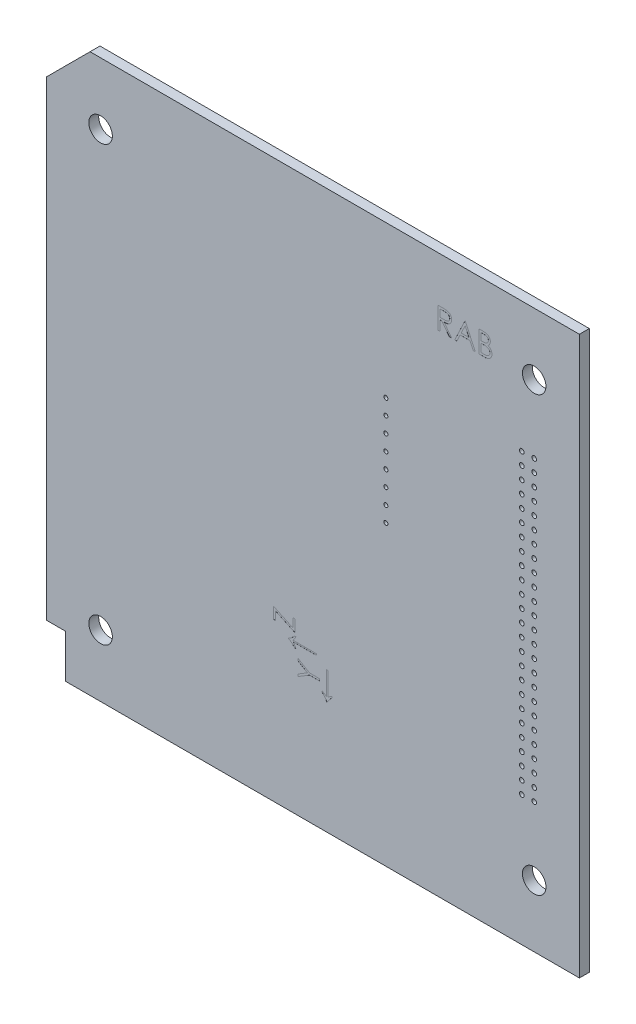
from build123d import *

# Parameters (mm, degrees)
SKETCH1_W           = 86
SKETCH1_H           = 90
SKETCH1_R           = 1.9
SKETCH1_R_2         = 0.375
SKETCH1_R_3         = 0.383755901
SKETCH1_R_4         = 0.384163196
SKETCH1_R_5         = 0.380771211
SKETCH1_R_6         = 0.377379225
SKETCH1_R_7         = 0.380832793
BOSS_EXTRUDE1_DEPTH = 1.6
SKETCH2_R           = 0.325
EXTRUDE1_DEPTH      = 2.6
CUT_EXTRUDE_1_DEPTH = 0.01
CUT_EXTRUDE_2_DEPTH = 0.01
SKETCH_3_W          = 3
SKETCH_3_H          = 7
CUT_EXTRUDE_3_DEPTH = 10


with BuildPart() as part:
    # Sketch1 → Boss-Extrude1 (new body)
    with BuildSketch(Plane.XY):
        with Locations((-43, -45)):
            Rectangle(SKETCH1_W, SKETCH1_H)
        with Locations((-7.3, -10)):
            Circle(SKETCH1_R, mode=Mode.SUBTRACT)
        with Locations((-77.3, -10)):
            Circle(SKETCH1_R, mode=Mode.SUBTRACT)
        with Locations((-77.3, -80)):
            Circle(SKETCH1_R, mode=Mode.SUBTRACT)
        with Locations((-7.3, -80)):
            Circle(SKETCH1_R, mode=Mode.SUBTRACT)
        with Locations((-9.3, -69)):
            Circle(SKETCH1_R_2, mode=Mode.SUBTRACT)
        with Locations((-7.3, -69)):
            Circle(SKETCH1_R_2, mode=Mode.SUBTRACT)
        with Locations((-7.3, -67)):
            Circle(SKETCH1_R_2, mode=Mode.SUBTRACT)
        with Locations((-9.3, -67)):
            Circle(SKETCH1_R_2, mode=Mode.SUBTRACT)
        with Locations((-9.3, -65)):
            Circle(SKETCH1_R_2, mode=Mode.SUBTRACT)
        with Locations((-7.3, -65)):
            Circle(SKETCH1_R_2, mode=Mode.SUBTRACT)
        with Locations((-7.3, -63)):
            Circle(SKETCH1_R_2, mode=Mode.SUBTRACT)
        with Locations((-9.3, -63)):
            Circle(SKETCH1_R_3, mode=Mode.SUBTRACT)
        with Locations((-9.3, -61)):
            Circle(SKETCH1_R_2, mode=Mode.SUBTRACT)
        with Locations((-7.3, -61)):
            Circle(SKETCH1_R_2, mode=Mode.SUBTRACT)
        with Locations((-7.3, -59)):
            Circle(SKETCH1_R_2, mode=Mode.SUBTRACT)
        with Locations((-9.3, -59)):
            Circle(SKETCH1_R_2, mode=Mode.SUBTRACT)
        with Locations((-7.3, -57)):
            Circle(SKETCH1_R_2, mode=Mode.SUBTRACT)
        with Locations((-9.3, -57)):
            Circle(SKETCH1_R_2, mode=Mode.SUBTRACT)
        with Locations((-9.3, -55)):
            Circle(SKETCH1_R_2, mode=Mode.SUBTRACT)
        with Locations((-7.3, -55)):
            Circle(SKETCH1_R_2, mode=Mode.SUBTRACT)
        with Locations((-7.3, -53)):
            Circle(SKETCH1_R_2, mode=Mode.SUBTRACT)
        with Locations((-9.3, -53)):
            Circle(SKETCH1_R_2, mode=Mode.SUBTRACT)
        with Locations((-9.3, -51)):
            Circle(SKETCH1_R_2, mode=Mode.SUBTRACT)
        with Locations((-7.3, -51)):
            Circle(SKETCH1_R_2, mode=Mode.SUBTRACT)
        with Locations((-7.3, -49)):
            Circle(SKETCH1_R_2, mode=Mode.SUBTRACT)
        with Locations((-9.3, -49)):
            Circle(SKETCH1_R_2, mode=Mode.SUBTRACT)
        with Locations((-9.3, -47)):
            Circle(SKETCH1_R_2, mode=Mode.SUBTRACT)
        with Locations((-7.3, -47)):
            Circle(SKETCH1_R_2, mode=Mode.SUBTRACT)
        with Locations((-7.3, -45)):
            Circle(SKETCH1_R_2, mode=Mode.SUBTRACT)
        with Locations((-9.3, -45)):
            Circle(SKETCH1_R_4, mode=Mode.SUBTRACT)
        with Locations((-9.3, -43)):
            Circle(SKETCH1_R_2, mode=Mode.SUBTRACT)
        with Locations((-7.3, -43)):
            Circle(SKETCH1_R_5, mode=Mode.SUBTRACT)
        with Locations((-7.3, -41)):
            Circle(SKETCH1_R_6, mode=Mode.SUBTRACT)
        with Locations((-9.3, -41)):
            Circle(SKETCH1_R_6, mode=Mode.SUBTRACT)
        with Locations((-9.3, -39)):
            Circle(SKETCH1_R_2, mode=Mode.SUBTRACT)
        with Locations((-7.3, -39)):
            Circle(SKETCH1_R_2, mode=Mode.SUBTRACT)
        with Locations((-7.3, -37)):
            Circle(SKETCH1_R_2, mode=Mode.SUBTRACT)
        with Locations((-9.3, -37)):
            Circle(SKETCH1_R_7, mode=Mode.SUBTRACT)
        with Locations((-7.3, -35)):
            Circle(SKETCH1_R_2, mode=Mode.SUBTRACT)
        with Locations((-9.3, -35)):
            Circle(SKETCH1_R_2, mode=Mode.SUBTRACT)
        with Locations((-9.3, -33)):
            Circle(SKETCH1_R_2, mode=Mode.SUBTRACT)
        with Locations((-7.3, -33)):
            Circle(SKETCH1_R_2, mode=Mode.SUBTRACT)
        with Locations((-7.3, -31)):
            Circle(SKETCH1_R_2, mode=Mode.SUBTRACT)
        with Locations((-9.3, -31)):
            Circle(SKETCH1_R_2, mode=Mode.SUBTRACT)
        with Locations((-7.3, -29)):
            Circle(SKETCH1_R_2, mode=Mode.SUBTRACT)
        with Locations((-9.3, -29)):
            Circle(SKETCH1_R_2, mode=Mode.SUBTRACT)
        with Locations((-9.3, -27)):
            Circle(SKETCH1_R_2, mode=Mode.SUBTRACT)
        with Locations((-7.3, -27)):
            Circle(SKETCH1_R_2, mode=Mode.SUBTRACT)
        with Locations((-7.3, -25)):
            Circle(SKETCH1_R_2, mode=Mode.SUBTRACT)
        with Locations((-9.3, -25)):
            Circle(SKETCH1_R_2, mode=Mode.SUBTRACT)
        with Locations((-7.3, -23)):
            Circle(SKETCH1_R_2, mode=Mode.SUBTRACT)
        with Locations((-9.3, -23)):
            Circle(SKETCH1_R_2, mode=Mode.SUBTRACT)
        with Locations((-9.3, -21)):
            Circle(SKETCH1_R_2, mode=Mode.SUBTRACT)
        with Locations((-7.3, -21)):
            Circle(SKETCH1_R_2, mode=Mode.SUBTRACT)
    extrude(amount=BOSS_EXTRUDE1_DEPTH)

    # Sketch2 → Extrude1 (cut, through all)
    with BuildSketch(Plane(origin=(0, 0, 0), x_dir=(-1, 0, 0), z_dir=(0, 0, -1))):
        with Locations((31.24, -24.5)):
            Circle(SKETCH2_R)
        with Locations((31.24, -27)):
            Circle(SKETCH2_R)
        with Locations((31.24, -29.5)):
            Circle(SKETCH2_R)
        with Locations((31.24, -32)):
            Circle(SKETCH2_R)
        with Locations((31.24, -34.5)):
            Circle(SKETCH2_R)
        with Locations((31.24, -37)):
            Circle(SKETCH2_R)
        with Locations((31.24, -39.5)):
            Circle(SKETCH2_R)
        with Locations((31.24, -42)):
            Circle(SKETCH2_R)
    extrude(amount=-EXTRUDE1_DEPTH, mode=Mode.SUBTRACT)

    # ｽｹｯﾁ1 → ｶｯﾄ - 押し出し1 (cut)
    with BuildSketch(Plane.XY.offset(1.6)):
        Polygon((-45.422907979, -70.570488191), (-45.422907979, -70.210812711), (-43.919001729, -69.290940916), (-45.422907979, -68.372471365), (-45.422907979, -68.012795884), (-43.586669998, -69.134590756), (-41.922907979, -69.134590756), (-41.922907979, -69.44869332), (-43.586669998, -69.44869332), align=None)
        Polygon((-49.042559529, -64.546795723), (-49.401533888, -64.546795723), (-49.401533888, -62.707052133), (-46.260508247, -64.175201171), (-46.260508247, -62.751923928), (-45.901533888, -62.751923928), (-45.901533888, -64.681411107), (-49.042559529, -63.213262069), align=None)
        with BuildLine():
            Line((-41.56393362, -70.795548288), (-41.56393362, -70.615359986))
            add(Edge.make_bspline(
                [(-41.56393362, -70.615359986), (-41.499275148, -70.647342808), (-41.370863205, -70.710860801), (-41.186484381, -70.818425521), (-41.011058478, -70.935514502), (-40.900873489, -71.02132933), (-40.845984902, -71.064077935)],
                knots=[0, 0, 0, 0, 0.000216356, 0.000429684, 0.000639892, 0.000848549, 0.000848549, 0.000848549, 0.000848549], degree=3))
            Line((-40.845984902, -71.064077935), (-40.845984902, -67.294847166))
            Line((-40.845984902, -67.294847166), (-40.621625927, -67.294847166))
            Line((-40.621625927, -67.294847166), (-40.621625927, -71.064077935))
            add(Edge.make_bspline(
                [(-40.621625927, -71.064077935), (-40.600816779, -71.0446585), (-40.557772691, -71.004489058), (-40.486789169, -70.947470675), (-40.408453665, -70.890330816), (-40.322628678, -70.833866724), (-40.228604195, -70.778342841), (-40.127292783, -70.723265113), (-40.018271274, -70.668434457), (-39.942574563, -70.633375374), (-39.903677209, -70.615359986)],
                knots=[0, 0, 0, 0, 8.5364e-05, 0.000176578, 0.00027292, 0.000376178, 0.000484637, 0.000600409, 0.000722067, 0.000850661, 0.000850661, 0.000850661, 0.000850661], degree=3))
            Line((-39.903677209, -70.615359986), (-39.903677209, -70.797651653))
            add(Edge.make_bspline(
                [(-39.903677209, -70.797651653), (-39.950753646, -70.841002938), (-40.042448627, -70.925442109), (-40.170801438, -71.054617033), (-40.287259171, -71.181411976), (-40.392178824, -71.305578527), (-40.485017832, -71.427258879), (-40.565088834, -71.547148407), (-40.635040188, -71.663686429), (-40.672272203, -71.743367976), (-40.690335863, -71.782026653)],
                knots=[0, 0, 0, 0, 0.00019197, 0.000373918, 0.00054611, 0.000708325, 0.000861453, 0.001004962, 0.001140721, 0.001268656, 0.001268656, 0.001268656, 0.001268656], degree=3))
            Line((-40.690335863, -71.782026653), (-40.792699645, -71.782026653))
            add(Edge.make_bspline(
                [(-40.792699645, -71.782026653), (-40.80825239, -71.745995378), (-40.840725997, -71.670763292), (-40.903281301, -71.558626453), (-40.979699583, -71.442315707), (-41.068767232, -71.320615708), (-41.173074063, -71.195665554), (-41.290558909, -71.065701156), (-41.421747945, -70.931214432), (-41.515501036, -70.84176013), (-41.56393362, -70.795548288)],
                knots=[0, 0, 0, 0, 0.000117676, 0.000245703, 0.000384553, 0.000535022, 0.000697865, 0.000872603, 0.001060516, 0.001261332, 0.001261332, 0.001261332, 0.001261332], degree=3))
        make_face()
        with BuildLine():
            Line((-45.947106805, -65.175000851), (-45.766918503, -65.175000851))
            add(Edge.make_bspline(
                [(-45.766918503, -65.175000851), (-45.798854445, -65.239687492), (-45.862189921, -65.367974273), (-45.970418722, -65.551943755), (-46.086822599, -65.72780807), (-46.172844311, -65.838089334), (-46.215636452, -65.892949569)],
                knots=[0, 0, 0, 0, 0.000216356, 0.000429078, 0.000639869, 0.000848526, 0.000848526, 0.000848526, 0.000848526], degree=3))
            Line((-46.215636452, -65.892949569), (-42.446405683, -65.892949569))
            Line((-42.446405683, -65.892949569), (-42.446405683, -66.117308543))
            Line((-42.446405683, -66.117308543), (-46.215636452, -66.117308543))
            add(Edge.make_bspline(
                [(-46.215636452, -66.117308543), (-46.196217017, -66.138117692), (-46.156047575, -66.18116178), (-46.099029192, -66.252145302), (-46.041889333, -66.330480805), (-45.985425241, -66.416305792), (-45.929901358, -66.510330275), (-45.87482363, -66.611641688), (-45.819992974, -66.720663196), (-45.784933891, -66.796359907), (-45.766918503, -66.835257261)],
                knots=[0, 0, 0, 0, 8.5364e-05, 0.000176578, 0.00027292, 0.000376178, 0.000484637, 0.000600409, 0.000722067, 0.000850661, 0.000850661, 0.000850661, 0.000850661], degree=3))
            Line((-45.766918503, -66.835257261), (-45.94921017, -66.835257261))
            add(Edge.make_bspline(
                [(-45.94921017, -66.835257261), (-45.992561455, -66.788180825), (-46.077000625, -66.696485843), (-46.20617555, -66.568133033), (-46.332970493, -66.451675299), (-46.457137043, -66.346755647), (-46.578817396, -66.253916639), (-46.698706924, -66.173845636), (-46.815244946, -66.103894283), (-46.894926493, -66.066662268), (-46.93358517, -66.048598607)],
                knots=[0, 0, 0, 0, 0.00019197, 0.000373918, 0.00054611, 0.000708325, 0.000861453, 0.001004962, 0.001140721, 0.001268656, 0.001268656, 0.001268656, 0.001268656], degree=3))
            Line((-46.93358517, -66.048598607), (-46.93358517, -65.946234825))
            add(Edge.make_bspline(
                [(-46.93358517, -65.946234825), (-46.897551608, -65.930685118), (-46.822314747, -65.898217853), (-46.710217249, -65.8356103), (-46.593621286, -65.759340687), (-46.47265015, -65.669320851), (-46.34693469, -65.565983816), (-46.217312941, -65.448309213), (-46.08275813, -65.317204983), (-45.993313599, -65.223439722), (-45.947106805, -65.175000851)],
                knots=[0, 0, 0, 0, 0.000117676, 0.000245703, 0.000384553, 0.000535438, 0.000697835, 0.000872573, 0.001060486, 0.001261302, 0.001261302, 0.001261302, 0.001261302], degree=3))
        make_face()
    extrude(amount=-CUT_EXTRUDE_1_DEPTH, mode=Mode.SUBTRACT)

    # ｽｹｯﾁ2 → ｶｯﾄ - 押し出し2 (cut)
    with BuildSketch(Plane.XY.offset(1.6)):
        with BuildLine():
            Line((-22.820494347, -7.351233874), (-22.120073674, -7.351233874))
            add(Edge.make_bspline(
                [(-22.120073674, -7.351233874), (-22.073332546, -7.35138946), (-21.983584401, -7.351688202), (-21.855011131, -7.353353965), (-21.738184034, -7.358128321), (-21.633164195, -7.362236904), (-21.53995354, -7.369728846), (-21.458266249, -7.376889493), (-21.388478552, -7.386263154), (-21.3462327, -7.394968576), (-21.327104924, -7.398910156)],
                knots=[0, 0, 0, 0, 0.000140226, 0.00026925, 0.000385712, 0.000490995, 0.000584507, 0.000666202, 0.000736998, 0.000795574, 0.000795574, 0.000795574, 0.000795574], degree=3))
            add(Edge.make_bspline(
                [(-21.327104924, -7.398910156), (-21.3014983, -7.405236921), (-21.250831311, -7.417755485), (-21.177881245, -7.444215086), (-21.108366921, -7.47483471), (-21.042577096, -7.510798431), (-20.980841305, -7.55237321), (-20.922522994, -7.598841333), (-20.867357531, -7.649948539), (-20.817575901, -7.70698338), (-20.770636849, -7.76681989), (-20.731048223, -7.831523647), (-20.696921743, -7.899185174), (-20.669751226, -7.970492592), (-20.647873253, -8.044754364), (-20.632447013, -8.12264316), (-20.623195826, -8.203804136), (-20.62225397, -8.259162044), (-20.621776399, -8.28723147)],
                knots=[0, 0, 0, 0, 7.9081e-05, 0.000156475, 0.000232432, 0.000306798, 0.00038108, 0.000455429, 0.000530331, 0.000606314, 0.000682321, 0.000758201, 0.000833453, 0.000909362, 0.000986794, 0.001065445, 0.001147284, 0.001231465, 0.001231465, 0.001231465, 0.001231465], degree=3))
            add(Edge.make_bspline(
                [(-20.621776399, -8.28723147), (-20.623245397, -8.333866575), (-20.626111793, -8.424863743), (-20.652836896, -8.556924624), (-20.696613416, -8.680113939), (-20.756936705, -8.794276577), (-20.833756181, -8.897187222), (-20.926080972, -8.987577677), (-21.033962583, -9.06321759), (-21.134391899, -9.115670394), (-21.223106099, -9.149263303), (-21.296139412, -9.172899662), (-21.375806389, -9.191161627), (-21.461343724, -9.207521759), (-21.553107379, -9.219873453), (-21.650877419, -9.228920048), (-21.75472357, -9.234574097), (-21.82606264, -9.235416101), (-21.862761976, -9.235849259)],
                knots=[0, 0, 0, 0, 0.000139777, 0.000272741, 0.000402249, 0.000530843, 0.000658588, 0.000786009, 0.000916741, 0.001052522, 0.001124656, 0.001201155, 0.001282612, 0.001369656, 0.001462366, 0.001560247, 0.001664165, 0.001774261, 0.001774261, 0.001774261, 0.001774261], degree=3))
            Line((-21.862761976, -9.235849259), (-20.576904604, -10.851233874))
            Line((-20.576904604, -10.851233874), (-20.965326078, -10.851233874))
            Line((-20.965326078, -10.851233874), (-22.25118345, -9.235849259))
            Line((-22.25118345, -9.235849259), (-22.506391783, -9.235849259))
            Line((-22.506391783, -9.235849259), (-22.506391783, -10.851233874))
            Line((-22.506391783, -10.851233874), (-22.820494347, -10.851233874))
            Line((-22.820494347, -10.851233874), (-22.820494347, -7.351233874))
        make_face()
        with BuildLine():
            Line((-22.506391783, -7.710208233), (-22.506391783, -8.8768749))
            Line((-22.506391783, -8.8768749), (-21.865566463, -8.881782752))
            add(Edge.make_bspline(
                [(-21.865566463, -8.881782752), (-21.835646424, -8.881795989), (-21.777652867, -8.881821645), (-21.693752202, -8.877827869), (-21.61563209, -8.873284551), (-21.543591338, -8.866335205), (-21.477597763, -8.857379133), (-21.41768435, -8.846176149), (-21.363753298, -8.833124087), (-21.300854759, -8.812922461), (-21.230618228, -8.780916442), (-21.154286768, -8.734350944), (-21.08928443, -8.675781825), (-21.034366568, -8.608808369), (-20.990237137, -8.53517212), (-20.959125082, -8.45575575), (-20.93938264, -8.372564152), (-20.937054094, -8.315386045), (-20.935878963, -8.286530348)],
                knots=[0, 0, 0, 0, 8.9746e-05, 0.000173954, 0.000251933, 0.000324488, 0.000391021, 0.000451663, 0.000507268, 0.000557378, 0.000649639, 0.000738152, 0.000824558, 0.000910739, 0.000997194, 0.001080909, 0.00116578, 0.001252248, 0.001252248, 0.001252248, 0.001252248], degree=3))
            add(Edge.make_bspline(
                [(-20.935878963, -8.286530348), (-20.937081084, -8.258383775), (-20.939463249, -8.202607536), (-20.958912018, -8.120951626), (-20.991801399, -8.043884675), (-21.036123637, -7.97172019), (-21.090122792, -7.906214455), (-21.153440605, -7.850167302), (-21.2243458, -7.803917837), (-21.290616998, -7.774363456), (-21.349851211, -7.756243603), (-21.401280871, -7.743492439), (-21.459392349, -7.73324797), (-21.524467807, -7.725039909), (-21.596229438, -7.717984965), (-21.675040089, -7.713233187), (-21.760376869, -7.710419322), (-21.8195238, -7.710280234), (-21.850141783, -7.710208233)],
                knots=[0, 0, 0, 0, 8.4371e-05, 0.000167192, 0.000250141, 0.000334794, 0.000420435, 0.000503871, 0.000587493, 0.000673488, 0.0007205, 0.000773215, 0.000832351, 0.0008974, 0.000969955, 0.001048634, 0.001134217, 0.001226067, 0.001226067, 0.001226067, 0.001226067], degree=3))
            Line((-21.850141783, -7.710208233), (-22.506391783, -7.710208233))
        make_face(mode=Mode.SUBTRACT)
        Polygon((-18.42305845, -7.351233874), (-16.807673835, -10.851233874), (-17.149120149, -10.851233874), (-17.666548033, -9.729439002), (-19.253186655, -9.729439002), (-19.785338097, -10.851233874), (-20.128186655, -10.851233874), (-18.467930245, -7.351233874), align=None)
        Polygon((-18.448999956, -8.03342538), (-19.082814059, -9.370464643), (-17.832012777, -9.370464643), align=None, mode=Mode.SUBTRACT)
        with BuildLine():
            Line((-16.179468706, -7.351233874), (-15.496576078, -7.351233874))
            add(Edge.make_bspline(
                [(-15.496576078, -7.351233874), (-15.4631476, -7.351409624), (-15.39835489, -7.351750272), (-15.304135448, -7.357033403), (-15.215886637, -7.364237073), (-15.133582865, -7.375667166), (-15.057262163, -7.389458943), (-14.986694525, -7.406160759), (-14.922104353, -7.426187373), (-14.844991617, -7.458033654), (-14.757070956, -7.505356822), (-14.661872563, -7.575285388), (-14.580468324, -7.660817851), (-14.510282006, -7.757300506), (-14.454480887, -7.863436278), (-14.414111589, -7.976695467), (-14.388553714, -8.095617209), (-14.38592528, -8.177260386), (-14.384596912, -8.218521534)],
                knots=[0, 0, 0, 0, 0.00010027, 0.000194349, 0.000283026, 0.000365821, 0.000443519, 0.000515622, 0.000583254, 0.00064614, 0.000765662, 0.000881909, 0.000998927, 0.001118415, 0.001238844, 0.00135727, 0.001478274, 0.001601912, 0.001601912, 0.001601912, 0.001601912], degree=3))
            add(Edge.make_bspline(
                [(-14.384596912, -8.218521534), (-14.38569013, -8.25717409), (-14.387838407, -8.333130007), (-14.408381167, -8.444224116), (-14.440541835, -8.549975335), (-14.485247084, -8.64999772), (-14.54334908, -8.742031334), (-14.612207399, -8.8268186), (-14.695284202, -8.900769657), (-14.757527442, -8.942112559), (-14.789144187, -8.96311288)],
                knots=[0, 0, 0, 0, 0.000115857, 0.00022767, 0.000337672, 0.000446877, 0.000555233, 0.000663318, 0.000773539, 0.000887324, 0.000887324, 0.000887324, 0.000887324], degree=3))
            add(Edge.make_bspline(
                [(-14.789144187, -8.96311288), (-14.74938376, -8.978377879), (-14.673312212, -9.007583604), (-14.5686262, -9.059219068), (-14.478431355, -9.115381178), (-14.402034209, -9.176713028), (-14.336696554, -9.242821839), (-14.279643612, -9.314676953), (-14.230962238, -9.393215711), (-14.189249315, -9.477619246), (-14.156700559, -9.567025715), (-14.132324654, -9.660596491), (-14.118357205, -9.757996046), (-14.116369564, -9.824281425), (-14.115366142, -9.857744291)],
                knots=[0, 0, 0, 0, 0.000127722, 0.000244363, 0.000349599, 0.000445847, 0.000537565, 0.000627901, 0.000720503, 0.000814257, 0.000909859, 0.001005428, 0.001103887, 0.001204268, 0.001204268, 0.001204268, 0.001204268], degree=3))
            add(Edge.make_bspline(
                [(-14.115366142, -9.857744291), (-14.116342988, -9.891911163), (-14.11826496, -9.959135441), (-14.132444932, -10.057890575), (-14.156454039, -10.152265522), (-14.189525185, -10.242870705), (-14.2326875, -10.329530839), (-14.285215464, -10.412344103), (-14.347847028, -10.490478434), (-14.417909897, -10.564802057), (-14.497172042, -10.631629844), (-14.582687797, -10.691145551), (-14.675534117, -10.740091613), (-14.774186111, -10.781207634), (-14.879750427, -10.812614833), (-14.991753035, -10.834587407), (-15.110097337, -10.849392444), (-15.191307088, -10.850609649), (-15.232954283, -10.851233874)],
                knots=[0, 0, 0, 0, 0.000102481, 0.000201635, 0.000298562, 0.000394165, 0.000490425, 0.000588455, 0.000687769, 0.000790423, 0.000894381, 0.000998232, 0.001102369, 0.001208616, 0.001318415, 0.001432129, 0.001550749, 0.00167562, 0.00167562, 0.00167562, 0.00167562], degree=3))
            Line((-15.232954283, -10.851233874), (-16.179468706, -10.851233874))
            Line((-16.179468706, -10.851233874), (-16.179468706, -7.351233874))
        make_face()
        with BuildLine():
            Line((-15.865366142, -7.710208233), (-15.865366142, -8.832003105))
            Line((-15.865366142, -8.832003105), (-15.654328482, -8.832003105))
            add(Edge.make_bspline(
                [(-15.654328482, -8.832003105), (-15.623479687, -8.831603182), (-15.563873527, -8.830830449), (-15.477553631, -8.828616932), (-15.397428613, -8.822418888), (-15.32363678, -8.816222626), (-15.256294336, -8.806148039), (-15.195550474, -8.794155916), (-15.140451877, -8.781473011), (-15.076912332, -8.759903524), (-15.004839383, -8.728025849), (-14.928006279, -8.678554012), (-14.86027181, -8.619629659), (-14.803074622, -8.551638698), (-14.756263151, -8.476772512), (-14.723749436, -8.396225631), (-14.701702152, -8.312005499), (-14.699710621, -8.254187246), (-14.698699476, -8.22483163)],
                knots=[0, 0, 0, 0, 9.2559e-05, 0.000178842, 0.000258967, 0.000333616, 0.000400942, 0.000463093, 0.000519379, 0.000570374, 0.000664201, 0.000755025, 0.000843472, 0.000932526, 0.001020669, 0.001107124, 0.001192318, 0.001280185, 0.001280185, 0.001280185, 0.001280185], degree=3))
            add(Edge.make_bspline(
                [(-14.698699476, -8.22483163), (-14.699225656, -8.205405859), (-14.700257816, -8.167300087), (-14.708711118, -8.111750733), (-14.723078693, -8.05950698), (-14.741532986, -8.00985287), (-14.767321675, -7.964341019), (-14.797685138, -7.921397824), (-14.834370828, -7.882485705), (-14.876128141, -7.846116207), (-14.924136764, -7.813871679), (-14.978368056, -7.785630916), (-15.039555733, -7.762890139), (-15.106668588, -7.742973987), (-15.180739675, -7.728985693), (-15.260914229, -7.717332305), (-15.347848948, -7.711399563), (-15.40799405, -7.7106142), (-15.439084091, -7.710208233)],
                knots=[0, 0, 0, 0, 5.8261e-05, 0.000114285, 0.000168029, 0.000220632, 0.000272728, 0.000324483, 0.000378062, 0.000432741, 0.000490301, 0.000551137, 0.000615721, 0.000685833, 0.000760908, 0.00084162, 0.000928788, 0.00102206, 0.00102206, 0.00102206, 0.00102206], degree=3))
            Line((-15.439084091, -7.710208233), (-15.865366142, -7.710208233))
        make_face(mode=Mode.SUBTRACT)
        with BuildLine():
            Line((-15.865366142, -9.190977464), (-15.865366142, -10.492259515))
            Line((-15.865366142, -10.492259515), (-15.418050437, -10.492259515))
            add(Edge.make_bspline(
                [(-15.418050437, -10.492259515), (-15.386031511, -10.491875768), (-15.324319253, -10.491136145), (-15.235218023, -10.48872159), (-15.152634919, -10.483229315), (-15.076946783, -10.474583465), (-15.00733633, -10.465205016), (-14.944638627, -10.452593735), (-14.888345434, -10.438144774), (-14.823071126, -10.415810602), (-14.749567618, -10.381114131), (-14.670356762, -10.328799905), (-14.599930543, -10.266476597), (-14.540125284, -10.194345683), (-14.491112296, -10.115914356), (-14.455456841, -10.032769006), (-14.433465984, -9.946283479), (-14.430803815, -9.887316766), (-14.429468706, -9.857744291)],
                knots=[0, 0, 0, 0, 9.6064e-05, 0.000185151, 0.000267373, 0.000344257, 0.000413665, 0.000478015, 0.000536005, 0.000587888, 0.000684801, 0.000778918, 0.000871787, 0.000965866, 0.001059062, 0.00114827, 0.001236355, 0.001324974, 0.001324974, 0.001324974, 0.001324974], degree=3))
            add(Edge.make_bspline(
                [(-14.429468706, -9.857744291), (-14.429744811, -9.83925095), (-14.430292566, -9.802562568), (-14.438553181, -9.748646749), (-14.450567051, -9.696420876), (-14.466098484, -9.645743135), (-14.488717952, -9.597529759), (-14.515124497, -9.550827199), (-14.546085898, -9.50557372), (-14.594330064, -9.448361467), (-14.664502049, -9.382444454), (-14.764208824, -9.317906951), (-14.877581122, -9.265859144), (-14.959808615, -9.243759668), (-15.002285213, -9.23234365)],
                knots=[0, 0, 0, 0, 5.5429e-05, 0.000109963, 0.000163198, 0.000216191, 0.000268588, 0.000322593, 0.000377046, 0.000432793, 0.000546889, 0.000664343, 0.000787646, 0.000919405, 0.000919405, 0.000919405, 0.000919405], degree=3))
            add(Edge.make_bspline(
                [(-15.002285213, -9.23234365), (-15.019314309, -9.228888566), (-15.056236901, -9.221397231), (-15.116444481, -9.213489527), (-15.18518035, -9.206444468), (-15.262603228, -9.20123331), (-15.348811069, -9.195846766), (-15.443987987, -9.193751945), (-15.547745302, -9.191252685), (-15.619737674, -9.191071551), (-15.657132969, -9.190977464)],
                knots=[0, 0, 0, 0, 5.2115e-05, 0.000112995, 0.000182062, 0.000259389, 0.000345767, 0.00044116, 0.000544948, 0.000657129, 0.000657129, 0.000657129, 0.000657129], degree=3))
            Line((-15.657132969, -9.190977464), (-15.865366142, -9.190977464))
        make_face(mode=Mode.SUBTRACT)
    extrude(amount=-CUT_EXTRUDE_2_DEPTH, mode=Mode.SUBTRACT)

    # ｽｹｯﾁ3 → ｶｯﾄ - 押し出し3 (cut)
    with BuildSketch(Plane(origin=(0, 0, 0), x_dir=(-1, 0, 0), z_dir=(0, 0, -1))):
        Polygon((86, 0), (86, -7), (79, 0), align=None)
        with Locations((84.5, -86.5)):
            Rectangle(SKETCH_3_W, SKETCH_3_H)
    extrude(amount=-CUT_EXTRUDE_3_DEPTH, mode=Mode.SUBTRACT)


solid = part.part
